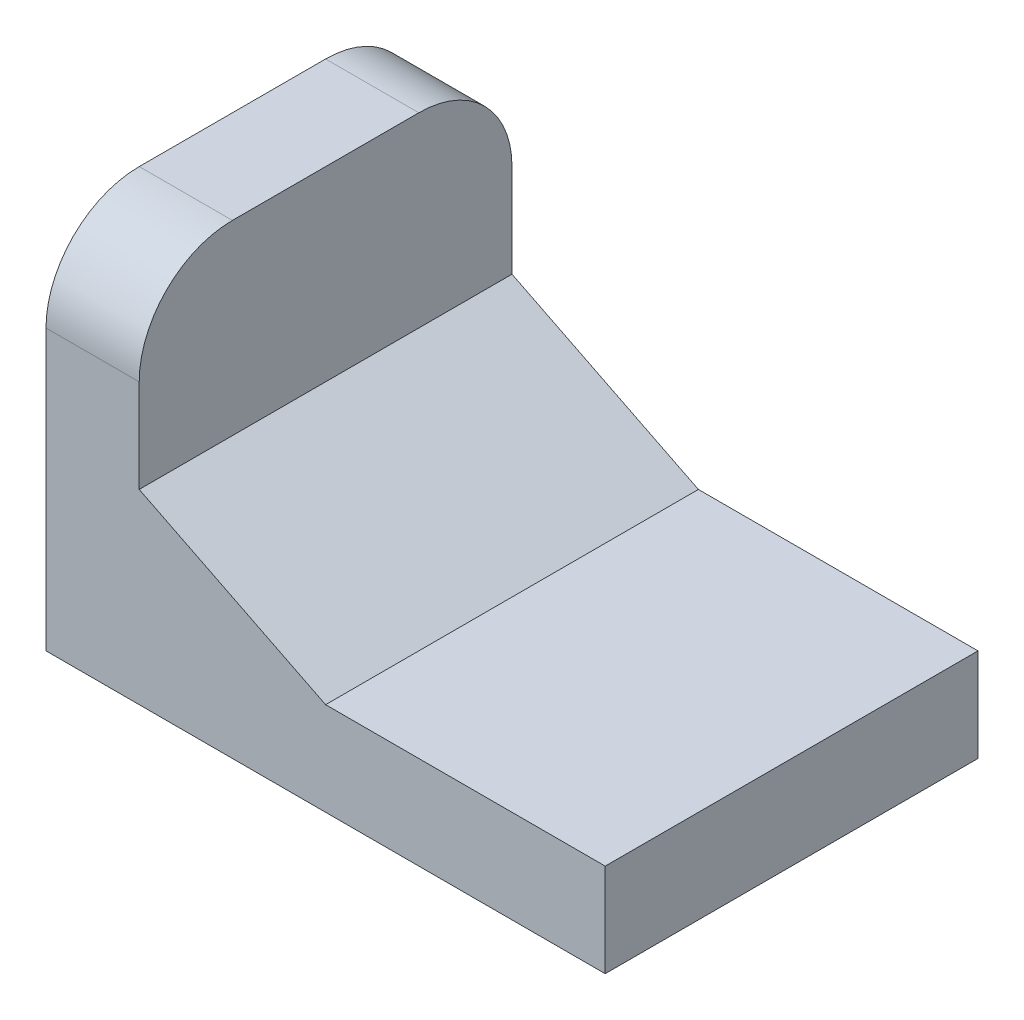
from build123d import *

# Parameters (mm, degrees)
EXTRUDE_1_DEPTH = 20
FILLET_1_R      = 5
SCALE_1_SCALE   = 0.2


with BuildPart() as part:
    # 草圖1 → 填料-伸長1 (new body)
    with BuildSketch(Plane.XY):
        Polygon((30, 5), (15, 5), (5, 10), (5, 20), (0, 20), (0, 5), (0, 0), (5, 0), (30, 0), align=None)
    extrude(amount=EXTRUDE_1_DEPTH)

    # 圓角1
    fillet_1_edges = [part.edges().sort_by_distance(p)[0] for p in [
        (2.5, 20, 20),
        (2.5, 20, 0),
    ]]
    fillet(fillet_1_edges, radius=FILLET_1_R)


with BuildPart() as part_1:
    # 縮放比例1: scaled about (10.67100901, 5.776025911, 10)
    add(part.part.scale(SCALE_1_SCALE).moved(Location((8.536807208, 4.620820729, 8))))


solid = part_1.part
